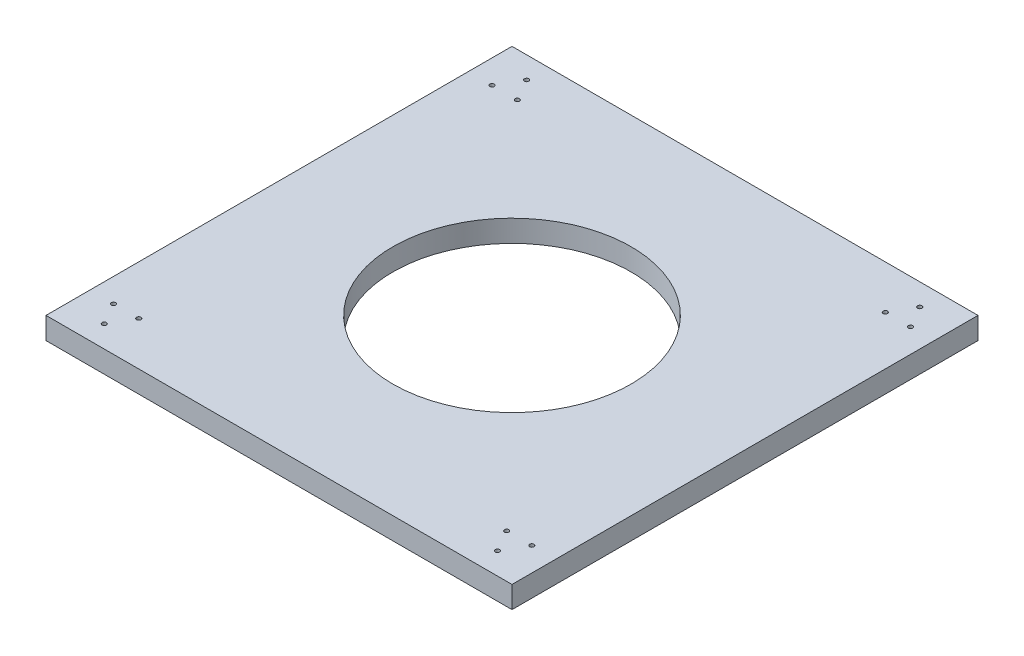
from build123d import *

# Parameters (mm, degrees)
SKETCH2_W           = 320
SKETCH2_H           = 320
SKETCH2_R           = 1.5
SKETCH2_R_2         = 81.767590035
BOSS_EXTRUDE1_DEPTH = 15


with BuildPart() as part:
    # Sketch2 → Boss-Extrude1 (new body)
    with BuildSketch(Plane(origin=(0, 0, 0), x_dir=(1, 0, 0), z_dir=(0, 1, 0))):
        with Locations((132.549861042, -98.505355986)):
            Rectangle(SKETCH2_W, SKETCH2_H)
        with Locations((267.549861042, 46.494644014)):
            Circle(SKETCH2_R, mode=Mode.SUBTRACT)
        with Locations((276.210115079, 31.494644014)):
            Circle(SKETCH2_R, mode=Mode.SUBTRACT)
        with Locations((258.889607004, 31.494644014)):
            Circle(SKETCH2_R, mode=Mode.SUBTRACT)
        with Locations((6.210115079, 31.494644014)):
            Circle(SKETCH2_R, mode=Mode.SUBTRACT)
        with Locations((-11.110392996, 31.494644014)):
            Circle(SKETCH2_R, mode=Mode.SUBTRACT)
        with Locations((-2.450138958, 46.494644014)):
            Circle(SKETCH2_R, mode=Mode.SUBTRACT)
        with Locations((-11.110392996, -228.505355986)):
            Circle(SKETCH2_R, mode=Mode.SUBTRACT)
        with Locations((6.210115079, -228.505355986)):
            Circle(SKETCH2_R, mode=Mode.SUBTRACT)
        with Locations((-2.450138958, -243.505355986)):
            Circle(SKETCH2_R, mode=Mode.SUBTRACT)
        with Locations((258.889607004, -228.505355986)):
            Circle(SKETCH2_R, mode=Mode.SUBTRACT)
        with Locations((276.210115079, -228.505355986)):
            Circle(SKETCH2_R, mode=Mode.SUBTRACT)
        with Locations((267.549861042, -243.505355986)):
            Circle(SKETCH2_R, mode=Mode.SUBTRACT)
        with Locations((132.549861042, -98.505355986)):
            Circle(SKETCH2_R_2, mode=Mode.SUBTRACT)
    extrude(amount=BOSS_EXTRUDE1_DEPTH)


solid = part.part
